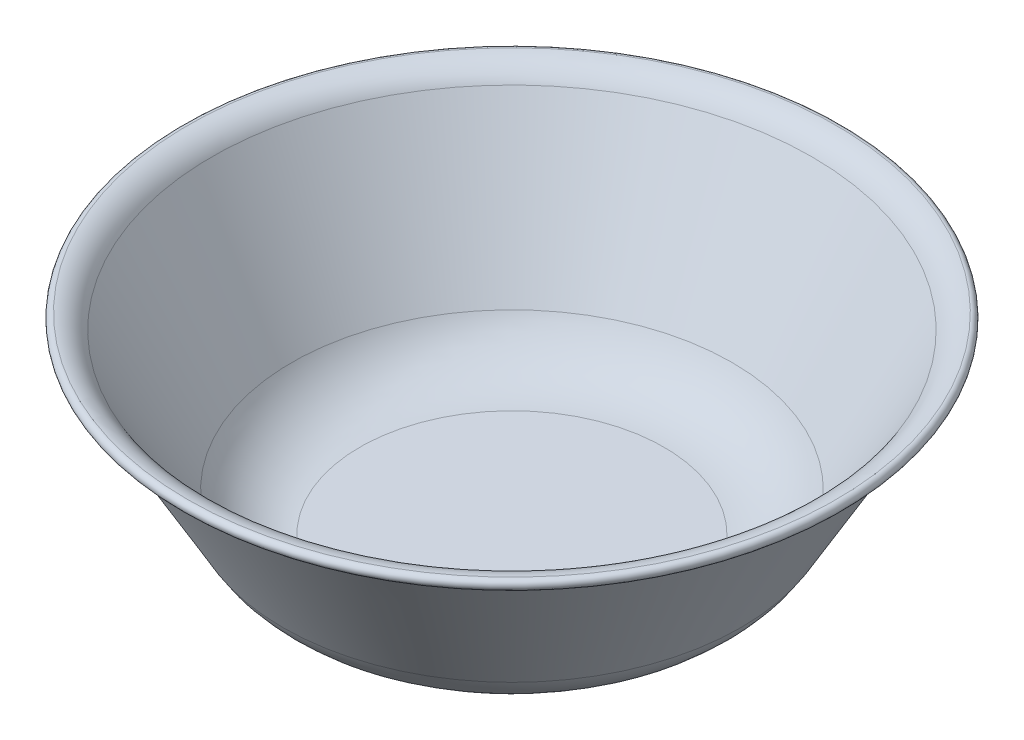
from build123d import *

# Parameters (mm, degrees)
SCALE1_SCALE = 0.5


with BuildPart() as part:
    # Sketch1 → Revolve1 (revolve)
    with BuildSketch(Plane.XY):
        with BuildLine():
            Line((0, 0), (60, 0))
            ThreePointArc((60, 0), (77.5, 4.689110868), (90.310889132, 17.5))
            Line((90.310889132, 17.5), (121.791448663, 72.025928557))
            ThreePointArc((121.791448663, 72.025928557), (124.472789107, 74.805615606), (128.143930379, 76.005185711))
            ThreePointArc((128.143930379, 76.005185711), (129.994814289, 78.143930379), (127.856069621, 79.994814289))
            ThreePointArc((127.856069621, 79.994814289), (122.349357715, 78.19545913), (118.327347047, 74.025928557))
            Line((118.327347047, 74.025928557), (86.846787517, 19.5))
            ThreePointArc((86.846787517, 19.5), (75.5, 8.153212483), (60, 4))
            Line((60, 4), (0, 4))
            Line((0, 4), (0, 0))
        make_face()
    revolve(axis=Axis((0, 4, 0), (0, -1, 0)))


with BuildPart() as part_1:
    # Scale1: scaled about (0, 35.690345414, 0)
    add(part.part.scale(SCALE1_SCALE).moved(Location((0, 17.845172707, 0))))


solid = part_1.part
